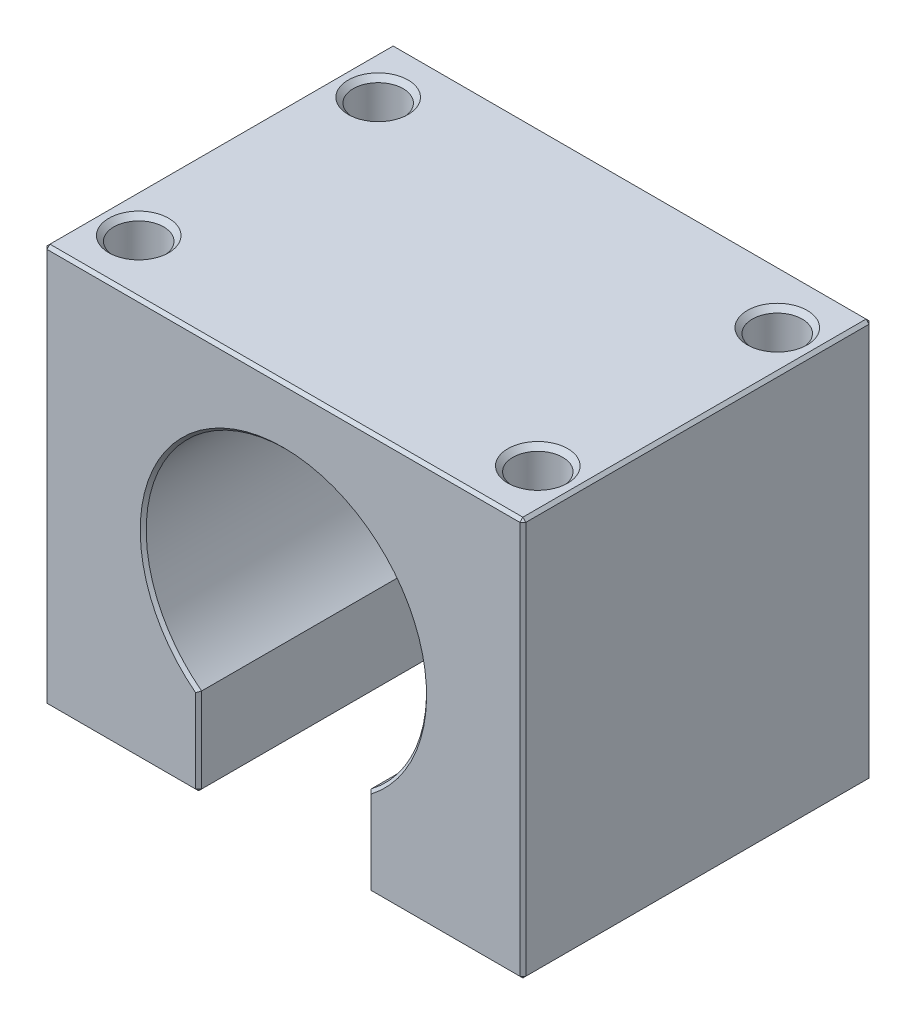
from build123d import *

# Parameters (mm, degrees)
BOSS_EXTRUDE1_DEPTH = 35
CHAMFER2_SIZE       = 0.3
SKETCH2_R           = 2.5
CUT_EXTRUDE1_DEPTH  = 17
SKETCH3_R           = 2.5
CUT_EXTRUDE2_DEPTH  = 20
CHAMFER3_SIZE       = 0.5


with BuildPart() as part:
    # Sketch1 → Boss-Extrude1 (new body)
    with BuildSketch(Plane.XY):
        with BuildLine():
            Line((24, 0), (-24, 0))
            Line((-24, 0), (-24, -40))
            Line((-24, -40), (-8.5, -40))
            Line((-8.5, -40), (-8.5, -31.187157816))
            ThreePointArc((-8.5, -31.187157816), (0, -5.95), (8.5, -31.187157816))
            Line((8.5, -31.187157816), (8.5, -40))
            Line((8.5, -40), (24, -40))
            Line((24, -40), (24, 0))
        make_face()
    extrude(amount=BOSS_EXTRUDE1_DEPTH)

    # Chamfer2
    chamfer2_edges = [part.edges().sort_by_distance(p)[0] for p in [
        (0, -5.95, 35),
        (-8.5, -35.593578908, 0),
        (-16.25, -40, 0),
        (8.5, -35.593578908, 35),
        (-24, -40, 17.5),
        (-24, 0, 17.5),
        (24, 0, 17.5),
        (24, -40, 17.5),
        (8.5, -40, 17.5),
        (-8.5, -40, 17.5),
        (16.25, -40, 35),
        (24, -20, 35),
        (0, 0, 35),
        (-24, -20, 35),
        (-16.25, -40, 35),
        (-8.5, -35.593578908, 35),
        (-24, -20, 0),
        (0, 0, 0),
        (24, -20, 0),
        (16.25, -40, 0),
        (8.5, -35.593578908, 0),
        (0, -5.95, 0),
    ]]
    chamfer(chamfer2_edges, length=CHAMFER2_SIZE)

    # Sketch2 → Cut-Extrude1 (cut)
    with BuildSketch(Plane(origin=(0, 0, 0), x_dir=(1, 0, 0), z_dir=(0, 1, 0))):
        with Locations((-20, -5.5)):
            Circle(SKETCH2_R)
        with Locations((20, -5.5)):
            Circle(SKETCH2_R)
        with Locations((20, -29.5)):
            Circle(SKETCH2_R)
        with Locations((-20, -29.5)):
            Circle(SKETCH2_R)
    extrude(amount=-CUT_EXTRUDE1_DEPTH, mode=Mode.SUBTRACT)

    # Sketch3 → Cut-Extrude2 (cut)
    with BuildSketch(Plane(origin=(0, 0, 0), x_dir=(-1, 0, 0), z_dir=(0, 0, -1))):
        with Locations((-13.435028843, -33.435028843)):
            Circle(SKETCH3_R)
        with Locations((13.435028843, -33.435028843)):
            Circle(SKETCH3_R)
        with Locations((13.435028843, -6.564971157)):
            Circle(SKETCH3_R)
        with Locations((-13.435028843, -6.564971157)):
            Circle(SKETCH3_R)
        with Locations((-19, -20)):
            Circle(SKETCH3_R)
        with Locations((19, -20)):
            Circle(SKETCH3_R)
    extrude(amount=-CUT_EXTRUDE2_DEPTH, mode=Mode.SUBTRACT)

    # Chamfer3
    chamfer3_edges = [part.edges().sort_by_distance(p)[0] for p in [
        (17.5, 0, 29.5),
        (-22.5, 0, 29.5),
        (15.935028843, -33.435028843, 0),
        (-10.935028843, -33.435028843, 0),
        (-10.935028843, -6.564971157, 0),
        (-16.5, -20, 0),
        (21.5, -20, 0),
        (-22.5, 0, 5.5),
        (17.5, 0, 5.5),
    ]]
    chamfer(chamfer3_edges, length=CHAMFER3_SIZE)


solid = part.part
